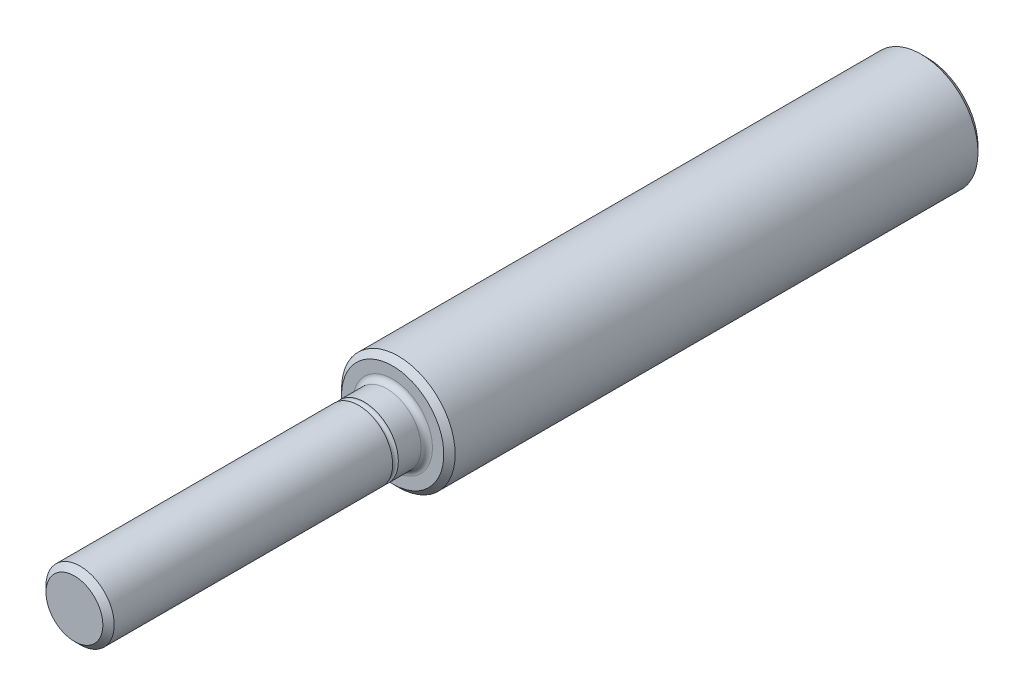
from build123d import *

# Parameters (mm, degrees)
FILLET1_R     = 0.5
CHAMFER1_SIZE = 0.5


with BuildPart() as part:
    # Sketch1 → Revolve1 (revolve)
    with BuildSketch(Plane(origin=(0, 0, 0), x_dir=(0, 0, -1), z_dir=(1, 0, 0))):
        with BuildLine():
            Line((-37.5, 0), (37.5, 0))
            Line((37.5, 0), (37.5, 5))
            Line((37.5, 5), (-9.5, 5))
            Line((-9.5, 5), (-9.5, 3))
            Line((-9.5, 3), (-12, 3))
            ThreePointArc((-12, 3), (-12.25, 2.75), (-12.5, 3))
            Line((-12.5, 3), (-37.5, 3))
            Line((-37.5, 3), (-37.5, 0))
        make_face()
    revolve(axis=Axis((0, 0, 258.883884114), (0, 0, -1)))

    # Fillet1
    fillet1_edges = [part.edges().sort_by_distance(p)[0] for p in [
        (0, -3, 9.5),
    ]]
    fillet(fillet1_edges, radius=FILLET1_R)

    # Chamfer1
    chamfer1_edges = [part.edges().sort_by_distance(p)[0] for p in [
        (0, -5, -37.5),
        (0, -3, 37.5),
        (0, -5, 9.5),
    ]]
    chamfer(chamfer1_edges, length=CHAMFER1_SIZE)


solid = part.part
